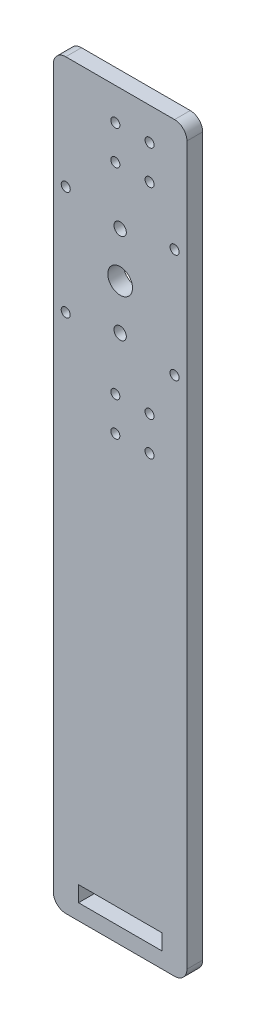
from build123d import *

# Parameters (mm, degrees)
SKETCH1_W              = 54
SKETCH1_H              = 300
BOSS_EXTRUDE1_DEPTH    = 6.35
FILLET1_R              = 5
SKETCH3_R              = 5
CUT_EXTRUDE1_DEPTH     = 7.35
F_6_CLEARANCE_HOLE1_D  = 3.6576
SKETCH6_W              = 33.65
SKETCH6_H              = 6.35
CUT_EXTRUDE2_DEPTH     = 7.35
F_10_CLEARANCE_HOLE2_D = 4.9784


with BuildPart() as part:
    # Sketch1 → Boss-Extrude1 (new body)
    with BuildSketch(Plane.XY):
        Rectangle(SKETCH1_W, SKETCH1_H)
    extrude(amount=BOSS_EXTRUDE1_DEPTH)

    # Fillet1
    fillet1_edges = [part.edges().sort_by_distance(p)[0] for p in [
        (-27, -150, 3.175),
        (-27, 150, 3.175),
        (27, 150, 3.175),
        (27, -150, 3.175),
    ]]
    fillet(fillet1_edges, radius=FILLET1_R)

    # Sketch3 → Cut-Extrude1 (cut, through all)
    with BuildSketch(Plane.XY.offset(6.35)):
        with Locations((0, 82.5)):
            Circle(SKETCH3_R)
    extrude(amount=-CUT_EXTRUDE1_DEPTH, mode=Mode.SUBTRACT)

    # #6 Clearance Hole1 (through all)
    with Locations(Plane.XY.offset(6.35)):
        with Locations((-22, 104.5), (-22, 60.5), (22, 60.5), (22, 104.5), (-1.944797213, 123.085202787), (-1.944797213, 136.914797213), (11.884797213, 136.914797213), (11.884797213, 123.085202787), (-1.944797213, 41.914797213), (11.884797213, 41.914797213), (11.884797213, 28.085202787), (-1.944797213, 28.085202787)):
            Hole(F_6_CLEARANCE_HOLE1_D / 2)

    # Sketch6 → Cut-Extrude2 (cut, through all)
    with BuildSketch(Plane.XY.offset(6.35)):
        with Locations((0, -140.475)):
            Rectangle(SKETCH6_W, SKETCH6_H)
    extrude(amount=-CUT_EXTRUDE2_DEPTH, mode=Mode.SUBTRACT)

    # #10 Clearance Hole2 (through all)
    with Locations(Plane.XY.offset(6.35)):
        with Locations((0, 64.25), (0, 100.75)):
            Hole(F_10_CLEARANCE_HOLE2_D / 2)


solid = part.part
